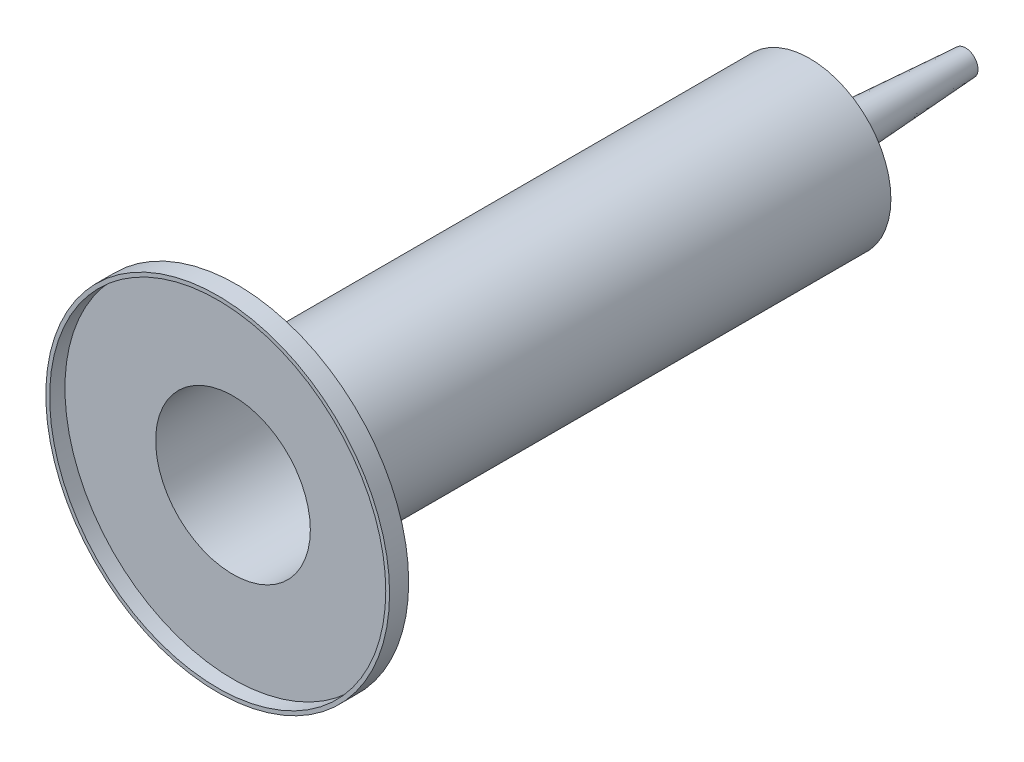
from build123d import *

# Parameters (mm, degrees)
SKETCH1_R           = 21.25
BOSS_EXTRUDE1_DEPTH = 150
SKETCH2_R           = 45
BOSS_EXTRUDE2_DEPTH = 5
SHELL1_T            = -1


with BuildPart() as part:
    # Sketch1 → Boss-Extrude1 (new body)
    with BuildSketch(Plane.XY):
        Circle(SKETCH1_R)
    extrude(amount=BOSS_EXTRUDE1_DEPTH)

    # Sketch2 → Boss-Extrude2 (add)
    with BuildSketch(Plane.XY.offset(150)):
        Circle(SKETCH2_R)
    extrude(amount=BOSS_EXTRUDE2_DEPTH)

    # Sketch4 → Revolve1 (revolve)
    with BuildSketch(Plane(origin=(0, 0, 0), x_dir=(0, 0, -1), z_dir=(1, 0, 0)), mode=Mode.PRIVATE) as revolve1_sk:
        Polygon((0, 21.25), (6.8, 5.35), (40.8, 3.25), (40.8, 0), (0, 0), align=None)
    revolve(revolve1_sk.sketch.rotate(Axis((0, 0, 0), (0, 0, -1)), 90), axis=Axis((0, 0, 0), (0, 0, -1)))

    # Shell1
    shell1_openings = [part.faces().sort_by_distance(p)[0] for p in [
        (0, 0, 155),
    ]]
    offset(amount=SHELL1_T, openings=shell1_openings, kind=Kind.INTERSECTION)


solid = part.part
